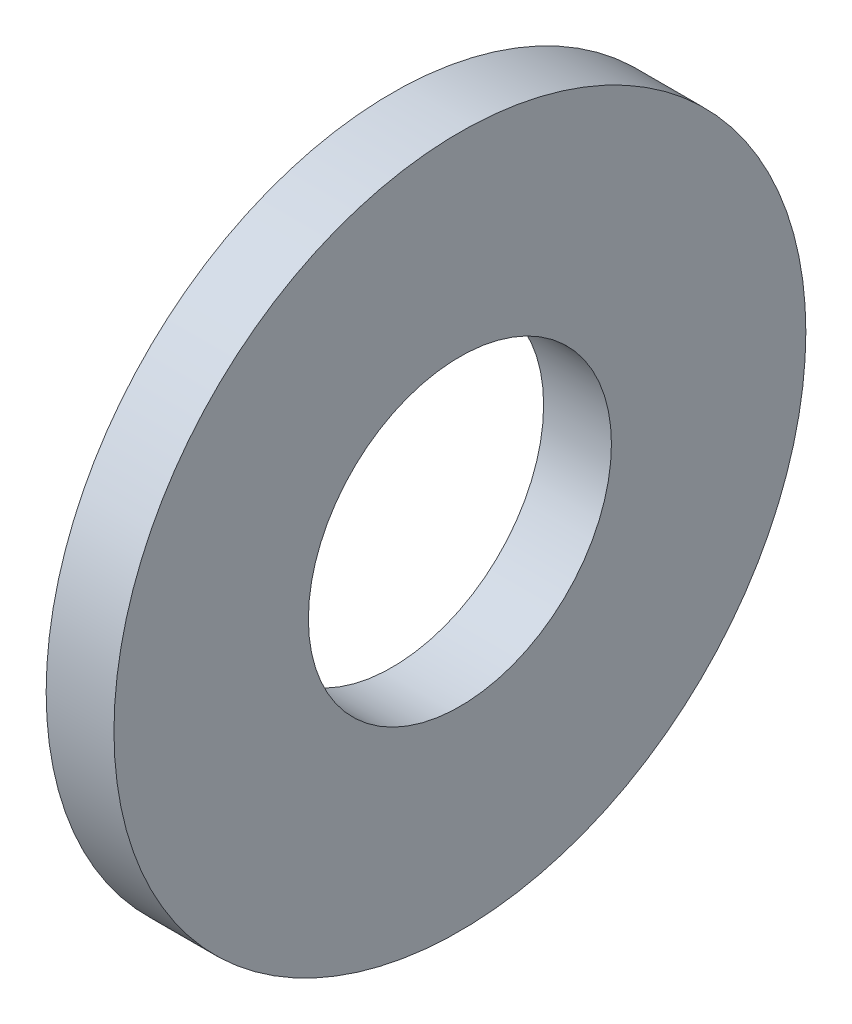
from build123d import *

# Parameters (mm, degrees)
SKETCH1_W = 1.2446
SKETCH1_H = 3.5687


with BuildPart() as part:
    # Sketch1 → Base-Revolve (revolve)
    with BuildSketch(Plane.XY):
        with Locations((-0.6223, 4.56565)):
            Rectangle(SKETCH1_W, SKETCH1_H)
    revolve(axis=Axis((-34.925, 0, 0), (1, 0, 0)))


solid = part.part
